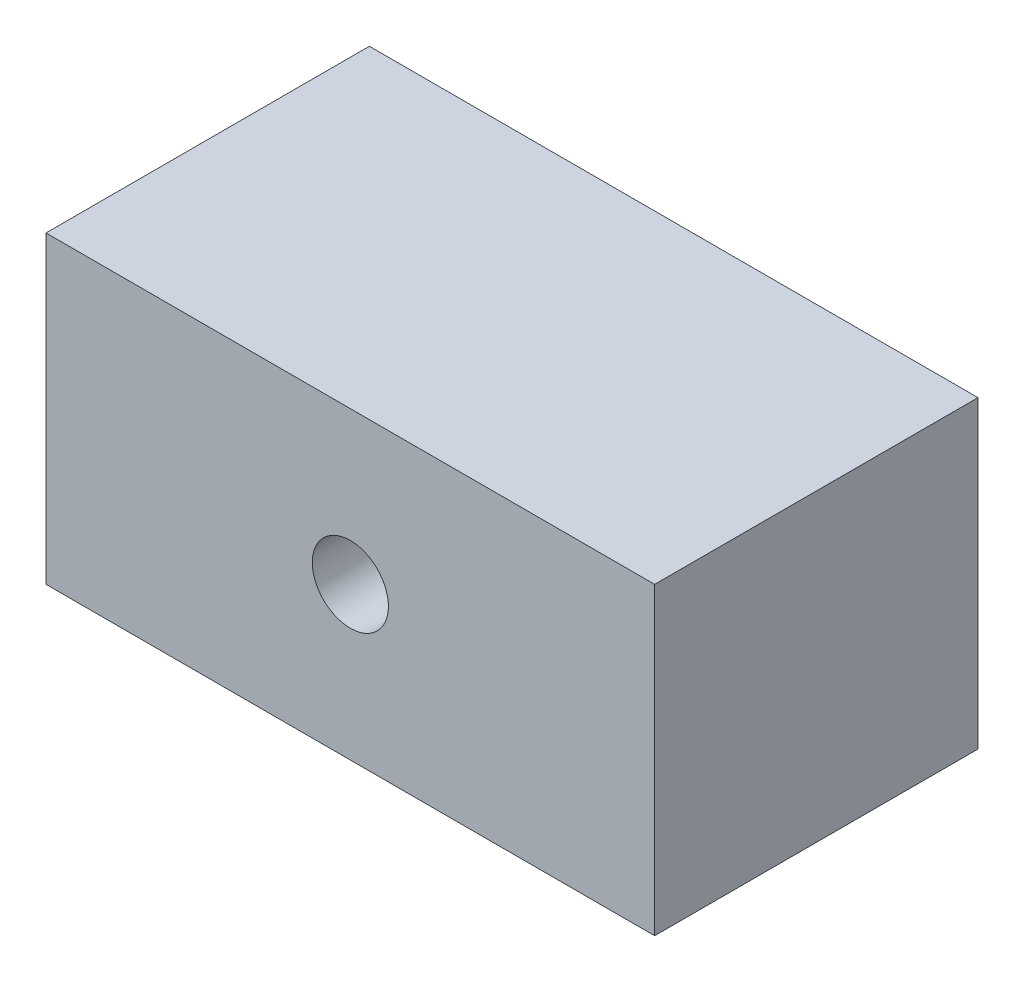
from build123d import *

# Parameters (mm, degrees)
SKETCH1_W                                           = 50.8
SKETCH1_H                                           = 25.4
BOSS_EXTRUDE1_DEPTH                                 = 26.9875
CBORE_FOR_0_BINDING_HEAD_MACHINE_SCREW1_D           = 6.35
CBORE_FOR_0_BINDING_HEAD_MACHINE_SCREW1_CBORE_D     = 15.875
CBORE_FOR_0_BINDING_HEAD_MACHINE_SCREW1_CBORE_DEPTH = 9.525


with BuildPart() as part:
    # Sketch1 → Boss-Extrude1 (new body)
    with BuildSketch(Plane.XY):
        Rectangle(SKETCH1_W, SKETCH1_H)
    extrude(amount=-BOSS_EXTRUDE1_DEPTH)

    # CBORE for #0 Binding Head Machine Screw1 (through all)
    with Locations(Plane(origin=(0, 0, -26.9875), x_dir=(-1, 0, 0), z_dir=(0, 0, -1))):
        with Locations((0, 0)):
            CounterBoreHole(CBORE_FOR_0_BINDING_HEAD_MACHINE_SCREW1_D / 2, CBORE_FOR_0_BINDING_HEAD_MACHINE_SCREW1_CBORE_D / 2, CBORE_FOR_0_BINDING_HEAD_MACHINE_SCREW1_CBORE_DEPTH)


solid = part.part
